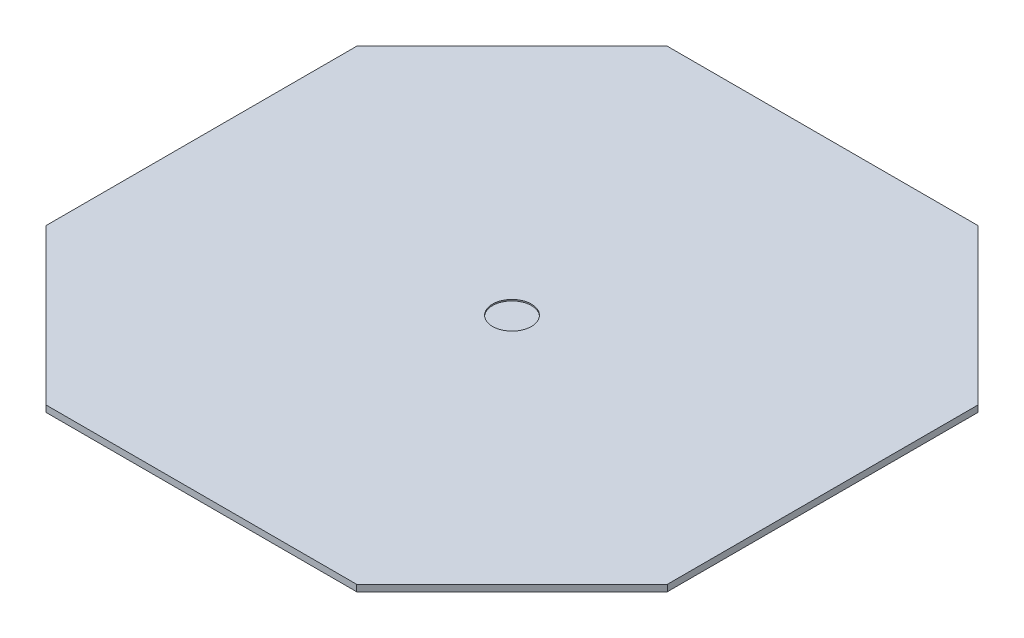
from build123d import *

# Parameters (mm, degrees)
BOSS_EXTRUDE1_DEPTH = 12.7
SKETCH2_R           = 38.1
CUT_EXTRUDE1_DEPTH  = 2.54


with BuildPart() as part:
    # Sketch1 → Boss-Extrude1 (new body)
    with BuildSketch(Plane(origin=(0, 0, 0), x_dir=(1, 0, 0), z_dir=(0, 1, 0))):
        Polygon((-609.6, 304.8), (-304.8, 609.6), (304.8, 609.6), (609.6, 304.8), (609.6, -304.8), (304.8, -609.6), (-304.8, -609.6), (-609.6, -304.8), align=None)
    extrude(amount=BOSS_EXTRUDE1_DEPTH)

    # Sketch2 → Cut-Extrude1 (cut)
    with BuildSketch(Plane(origin=(0, 12.7, 0), x_dir=(1, 0, 0), z_dir=(0, 1, 0))):
        Circle(SKETCH2_R)
    extrude(amount=-CUT_EXTRUDE1_DEPTH, mode=Mode.SUBTRACT)


solid = part.part
